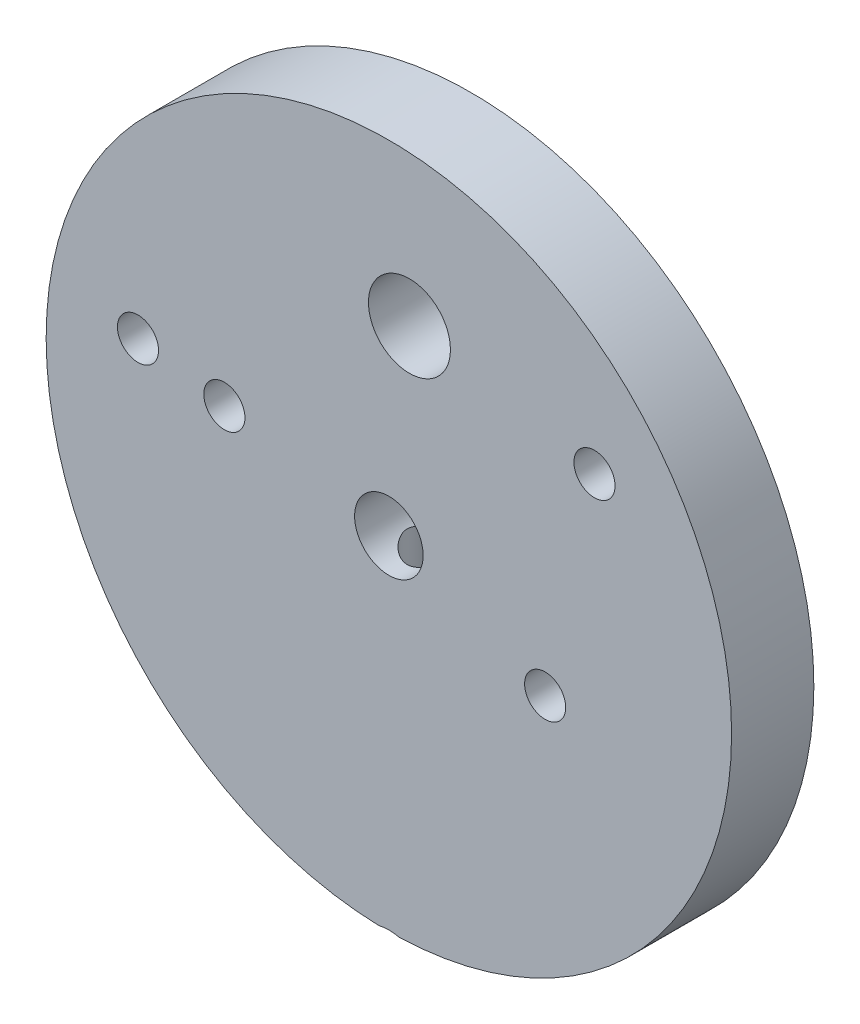
from build123d import *

# Parameters (mm, degrees)
ESQUISSE1_R               = 25
ESQUISSE1_R_2             = 1.5
ESQUISSE1_R_3             = 2.99
ESQUISSE1_R_4             = 2.5
EXTRUSION1_DEPTH          = 3
TROU_TARAUD_M4X0_71_D     = 3.3
TROU_TARAUD_M4X0_71_DEPTH = 7.5
TROU_TARAUD_M4X0_71_TIP   = 0.991420021


with BuildPart() as part:
    # Esquisse1 → Extrusion1 (new body, symmetric)
    with BuildSketch(Plane.XY):
        Circle(ESQUISSE1_R)
        with Locations((-18.3, 3.3)):
            Circle(ESQUISSE1_R_2, mode=Mode.SUBTRACT)
        with Locations((-12, 2.2)):
            Circle(ESQUISSE1_R_2, mode=Mode.SUBTRACT)
        with Locations((1.5, 14)):
            Circle(ESQUISSE1_R_3, mode=Mode.SUBTRACT)
        Circle(ESQUISSE1_R_4, mode=Mode.SUBTRACT)
        with Locations((15, 11.4)):
            Circle(ESQUISSE1_R_2, mode=Mode.SUBTRACT)
        with Locations((11.4, -4.4)):
            Circle(ESQUISSE1_R_2, mode=Mode.SUBTRACT)
    extrude(amount=EXTRUSION1_DEPTH, both=True)

    # Esquisse2 → Enlèvement de matière-Révolution1 (revolve, cut)
    with BuildSketch(Plane.XY, mode=Mode.PRIVATE) as enl_vement_de_mati_re_r_volution1_sk:
        Polygon((0, -7.5), (0, -25), (-3.1, -25), (-2.1, -24), (-2.1, -7.5), align=None)
    revolve(enl_vement_de_mati_re_r_volution1_sk.sketch.rotate(Axis((0, -7.5, 0), (0, -1, 0)), 103.797774305), axis=Axis((0, -7.5, 0), (0, -1, 0)), mode=Mode.SUBTRACT)  # turned: the seam where the file's is

    # Trou taraudé M4x0.71
    with Locations(Plane(origin=(0, -7.5, 0), x_dir=(-1, 0, 0), z_dir=(0, -1, 0))):
        with Locations((0, 0)):
            Hole(TROU_TARAUD_M4X0_71_D / 2, depth=TROU_TARAUD_M4X0_71_DEPTH)
            with Locations((0, 0, -(TROU_TARAUD_M4X0_71_DEPTH + TROU_TARAUD_M4X0_71_TIP / 2))):  # 118° drill point
                Cone(0, TROU_TARAUD_M4X0_71_D / 2, TROU_TARAUD_M4X0_71_TIP, mode=Mode.SUBTRACT)


solid = part.part
